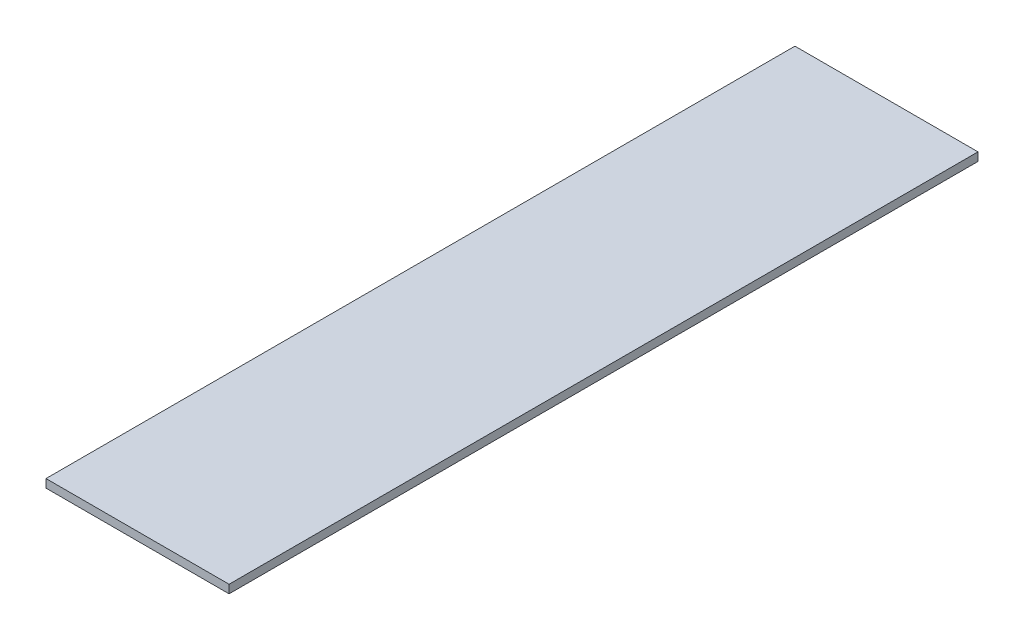
from build123d import *

# Parameters (mm, degrees)
SKETCH1_W           = 139.7
SKETCH1_H           = 571.5
BOSS_EXTRUDE1_DEPTH = 6.35


with BuildPart() as part:
    # Sketch1 → Boss-Extrude1 (new body)
    with BuildSketch(Plane(origin=(0, 0, 0), x_dir=(1, 0, 0), z_dir=(0, 1, 0))):
        with Locations((-69.85, 60.157894737)):
            Rectangle(SKETCH1_W, SKETCH1_H)
    extrude(amount=-BOSS_EXTRUDE1_DEPTH)


solid = part.part
